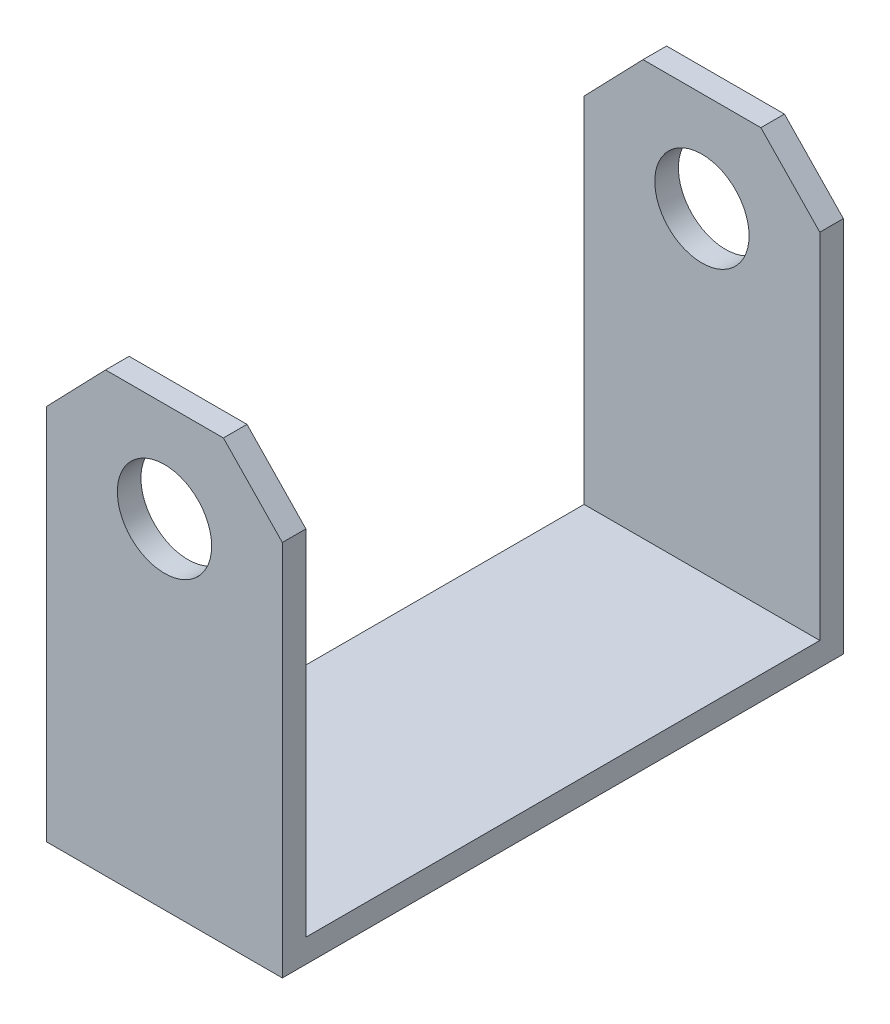
from build123d import *

# Parameters (mm, degrees)
SKETCH4_R           = 2.54
BOSS_EXTRUDE1_DEPTH = 1.27
SKETCH5_W           = 12.7
SKETCH5_H           = 1.27
BOSS_EXTRUDE2_DEPTH = 28.956


with BuildPart() as part:
    # Sketch4 → Boss-Extrude1 (new body)
    with BuildSketch(Plane.XY):
        Polygon((0, 0), (12.7, 0), (12.7, 20.32), (9.525, 23.609765797), (3.175, 23.609765797), (0, 20.32), align=None)
        with Locations((6.35, 18.246144904)):
            Circle(SKETCH4_R, mode=Mode.SUBTRACT)
    boss_extrude1 = extrude(amount=BOSS_EXTRUDE1_DEPTH)

    # Sketch5 → Boss-Extrude2 (add)
    with BuildSketch(Plane.XY.offset(1.27)):
        with Locations((6.35, 0.635)):
            Rectangle(SKETCH5_W, SKETCH5_H)
    extrude(amount=BOSS_EXTRUDE2_DEPTH)

    # Mirror1: Boss-Extrude1 across plane
    add(boss_extrude1.mirror(Plane.XY.offset(15.113)))


solid = part.part
